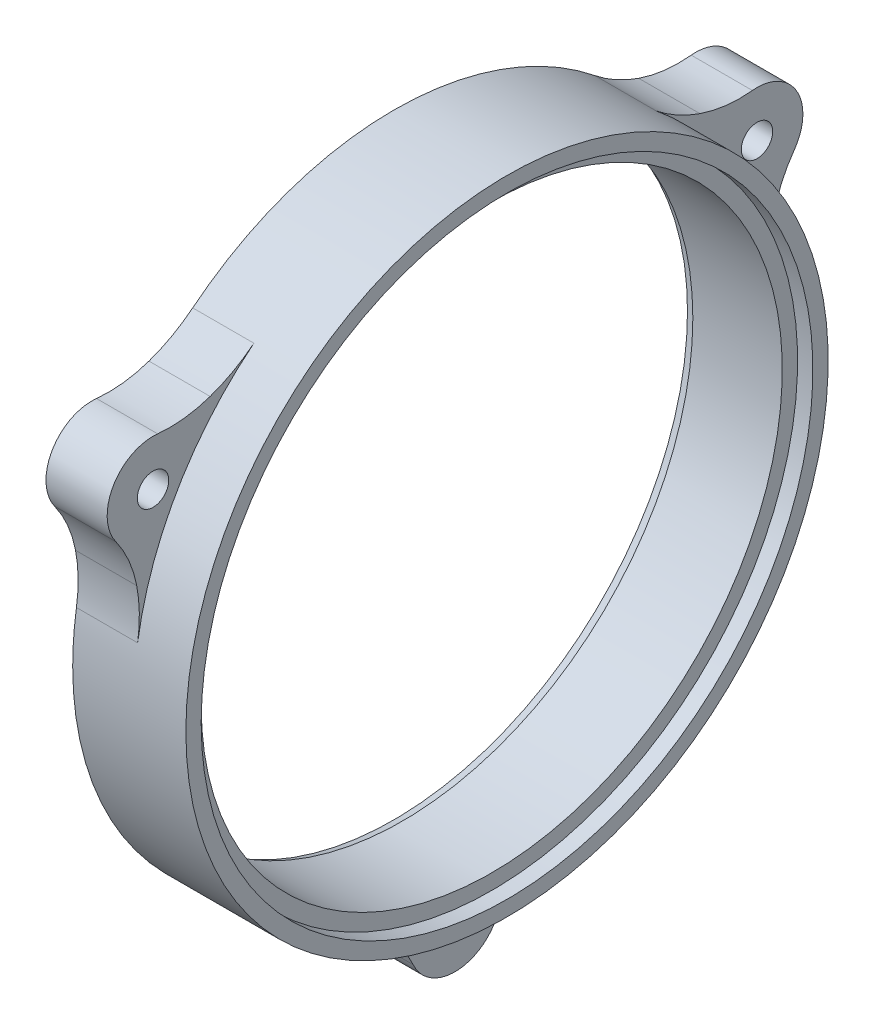
from build123d import *

# Parameters (mm, degrees)
BOSS_EXTRUDE1_DEPTH     = 12.7
F_1_4_CLEARANCE_HOLE1_D = 6.5278
CIRPATTERN1_COUNT       = 3
CHAMFER1_SIZE2          = 1.744648161
CHAMFER1_SIZE           = 0.635


with BuildPart() as part:
    # Sketch1 → Revolve1 (revolve)
    with BuildSketch(Plane.XY):
        Polygon((0, 66.675), (23.495, 66.675), (23.495, 63.5), (20.32, 63.5), (20.32, 60.325), (0, 60.325), align=None)
    revolve(axis=Axis((0, 0, 0), (1, 0, 0)))

    # Sketch5 → Boss-Extrude1 (add)
    with BuildSketch(Plane.ZY):
        with BuildLine():
            ThreePointArc((-61.733643772, 45.671707505), (-70.940470951, 40.9575), (-70.41968082, 30.627050022))
            ThreePointArc((-70.41968082, 30.627050022), (-67.700076965, 25.827577718), (-66.080812198, 20.554138506))
            ThreePointArc((-66.080812198, 20.554138506), (-65.542300069, 15.371802621), (-65.894280688, 10.17346537))
            ThreePointArc((-65.894280688, 10.17346537), (-57.742243797, 33.3375), (-41.757619799, 51.979388355))
            ThreePointArc((-41.757619799, 51.979388355), (-46.083521606, 49.075395572), (-50.840812198, 46.950592813))
            ThreePointArc((-50.840812198, 46.950592813), (-56.217376905, 45.716197631), (-61.733643772, 45.671707505))
        make_face()
    boss_extrude1 = extrude(amount=-BOSS_EXTRUDE1_DEPTH)

    # 1/4 Clearance Hole1 (through all)
    with Locations(Plane.ZY):
        with Locations((-62.69157898, 36.195)):
            f_1_4_clearance_hole1 = Hole(F_1_4_CLEARANCE_HOLE1_D / 2)

    # CirPattern1: Boss-Extrude1, 1/4 Clearance Hole1 ×3 about axis
    cirpattern1_axis = Axis((0, 0, 0), (1, 0, 0))
    for i in range(1, CIRPATTERN1_COUNT):
        add(boss_extrude1.rotate(cirpattern1_axis, i * 360 / CIRPATTERN1_COUNT))
        add(f_1_4_clearance_hole1.rotate(cirpattern1_axis, i * 360 / CIRPATTERN1_COUNT), mode=Mode.SUBTRACT)

    # Chamfer1
    chamfer1_edges = [part.edges().sort_by_distance(p)[0] for p in [
        (0, -60.325, 0),
    ]]
    chamfer(chamfer1_edges, length=CHAMFER1_SIZE, length2=CHAMFER1_SIZE2)


solid = part.part
